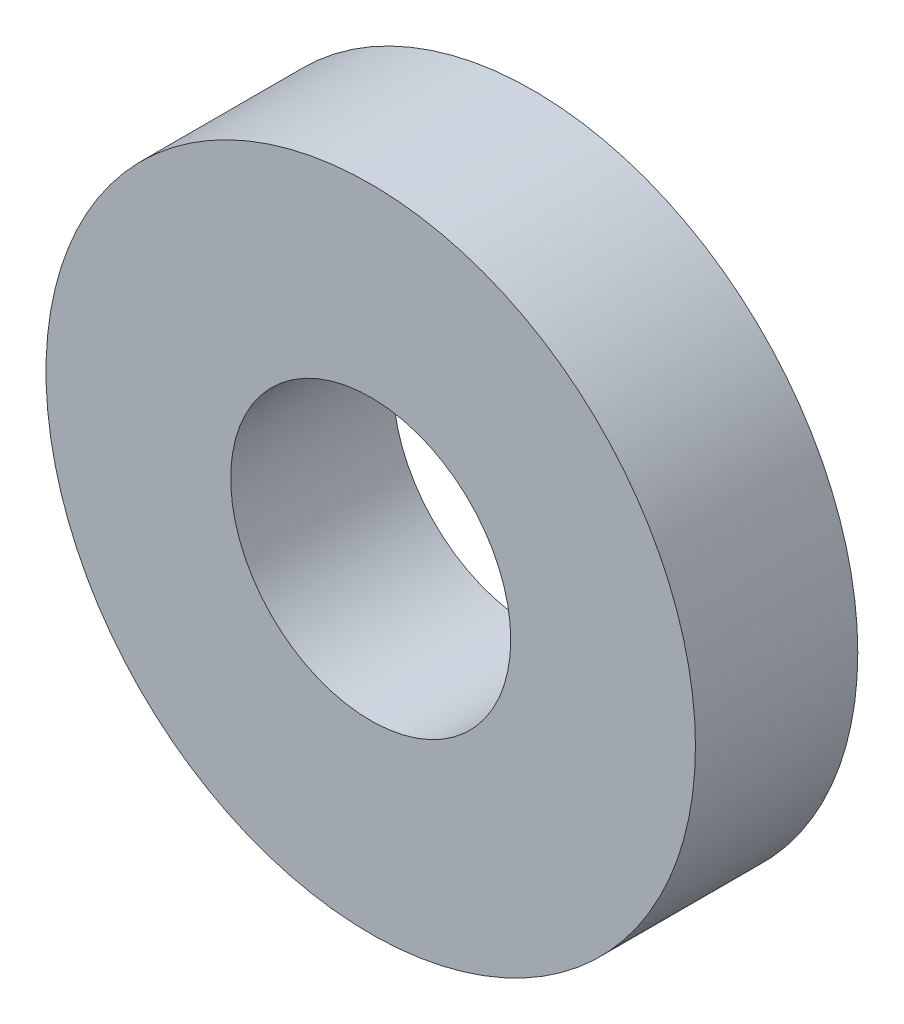
from build123d import *

# Parameters (mm, degrees)
SKETCH1_R         = 4
SKETCH1_R_2       = 1.725
MAIN_SPACER_DEPTH = 2


with BuildPart() as part:
    # Sketch1 → Main Spacer (new body)
    with BuildSketch(Plane.XY):
        Circle(SKETCH1_R)
        Circle(SKETCH1_R_2, mode=Mode.SUBTRACT)
    extrude(amount=MAIN_SPACER_DEPTH)


solid = part.part
